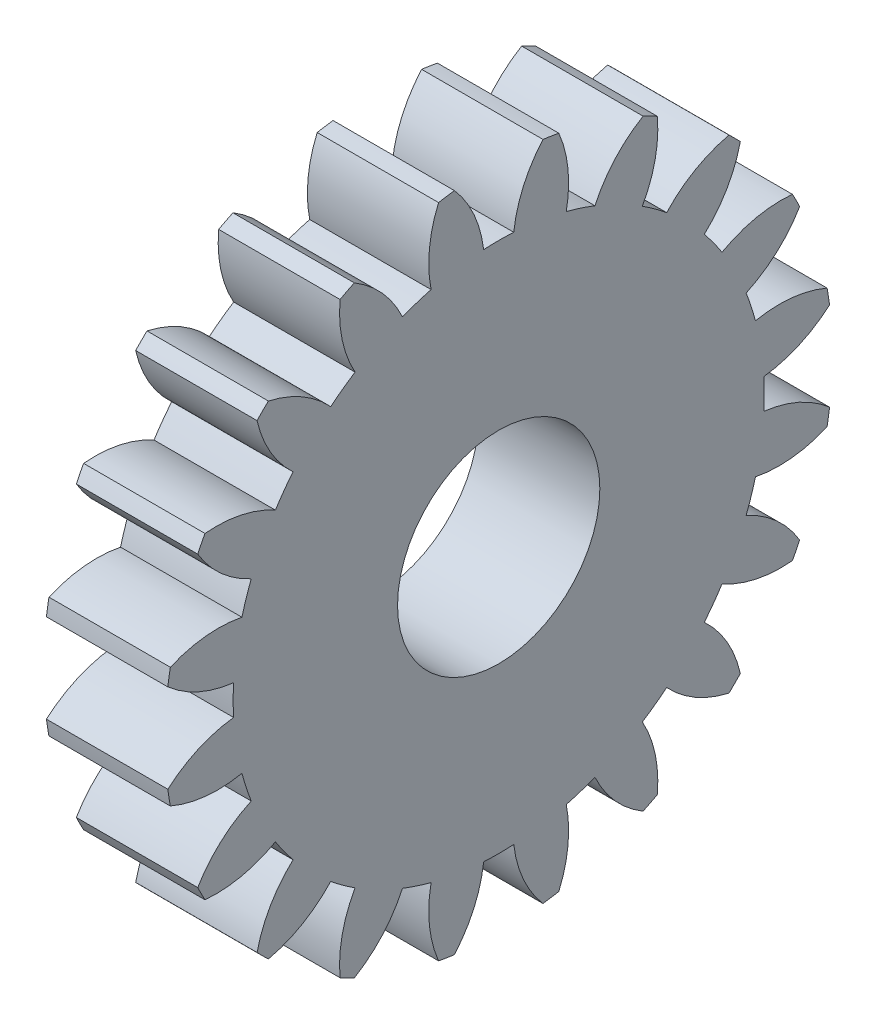
from build123d import *

# Parameters (mm, degrees)
BASPROSKE_W     = 6
BASPROSKE_H     = 16.5
TOOTHCUT_DEPTH  = 25.093567606
TEETHCUTS_COUNT = 20
TEETHCUTS_ANGLE = 342
BORSKE_R        = 5
BORE_DEPTH      = 50.0000508


with BuildPart() as part:
    # BasProSke → Base-Revolve (revolve)
    with BuildSketch(Plane(origin=(0, 0, 0), x_dir=(1, 0, 0), z_dir=(0, 1, 0)), mode=Mode.PRIVATE) as base_revolve_sk:
        with Locations((3, 8.25)):
            Rectangle(BASPROSKE_W, BASPROSKE_H)
    revolve(base_revolve_sk.sketch.rotate(Axis((-10, 0, 0), (1, 0, 0)), 180), axis=Axis((-10, 0, 0), (1, 0, 0)))

    # TooCutSke → ToothCut (cut, through all)
    with BuildSketch(Plane(origin=(0, 0, 0), x_dir=(0, 0, -1), z_dir=(1, 0, 0))):
        with BuildLine():
            ThreePointArc((0.74381438, 13.102904875), (0, 13.124), (-0.74381438, 13.102904875))
            ThreePointArc((-0.74381438, 13.102904875), (-1.226473103, 14.852072512), (-2.209965745, 16.376962373))
            ThreePointArc((-2.209965745, 16.376962373), (0, 16.5254), (2.209965745, 16.376962373))
            ThreePointArc((2.209965745, 16.376962373), (1.226473103, 14.852072512), (0.74381438, 13.102904875))
        make_face()
    toothcut = extrude(amount=TOOTHCUT_DEPTH, mode=Mode.SUBTRACT)

    # TeethCuts: ToothCut ×20 about axis
    teethcuts_axis = Axis((-10, 0, 0), (1, 0, 0))
    for i in range(1, TEETHCUTS_COUNT):
        add(toothcut.rotate(teethcuts_axis, i * TEETHCUTS_ANGLE / (TEETHCUTS_COUNT - 1)), mode=Mode.SUBTRACT)

    # BorSke → Bore (cut, symmetric)
    with BuildSketch(Plane(origin=(0, 0, 0), x_dir=(0, 0, -1), z_dir=(1, 0, 0))):
        with Locations(Location((0, 0, 0), (0, 0, 180))):
            Circle(BORSKE_R)
    extrude(amount=BORE_DEPTH, both=True, mode=Mode.SUBTRACT)


solid = part.part
